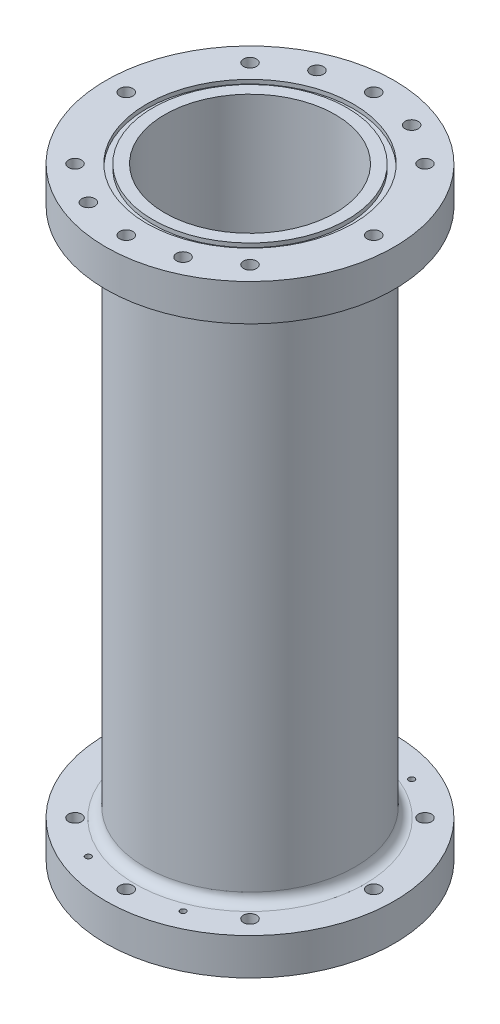
from build123d import *

# Parameters (mm, degrees)
SKETCH2_R               = 50.8
SKETCH2_R_2             = 41.275
BASE_CYLINDER_DEPTH     = 292.1
SKETCH3_R               = 69.85
SKETCH3_R_2             = 41.275
AFT_FLANGE_DEPTH        = 17.78
SKETCH4_R               = 69.85
SKETCH4_R_2             = 41.275
FORWARD_FLANGE_DEPTH    = 17.78
SKETCH6_R               = 50.0761
SKETCH6_R_2             = 47.0027
O_RING_SLOT_1_DEPTH     = 1.9812
SKETCH7_R               = 50.0761
SKETCH7_R_2             = 47.0027
O_RING_SLOT_2_DEPTH     = 1.9812
SKETCH8_R               = 3.175
CUT_EXTRUDE4_DEPTH      = 1
CUT_EXTRUDE4_DEPTH_BACK = 293.1
FILLET1_R               = 4.7625
SKETCH9_R               = 3.175
CUT_EXTRUDE5_DEPTH      = 7.62
SKETCH10_R              = 3.175
CUT_EXTRUDE6_DEPTH      = 7.62
CUT_EXTRUDE7_REACH      = 286.48
SKETCH11_R              = 1.4097
CUT_EXTRUDE8_REACH      = 286.48
SKETCH12_R              = 1.4097


with BuildPart() as part:
    # Sketch2 → Base Cylinder (new body)
    with BuildSketch(Plane(origin=(0, 0, 0), x_dir=(1, 0, 0), z_dir=(0, 1, 0))):
        Circle(SKETCH2_R)
        Circle(SKETCH2_R_2, mode=Mode.SUBTRACT)
    extrude(amount=BASE_CYLINDER_DEPTH)

    # Sketch3 → Aft Flange (add)
    with BuildSketch(Plane.XZ):
        Circle(SKETCH3_R)
        Circle(SKETCH3_R_2, mode=Mode.SUBTRACT)
    extrude(amount=-AFT_FLANGE_DEPTH)

    # Sketch4 → Forward Flange (add)
    with BuildSketch(Plane(origin=(0, 292.1, 0), x_dir=(1, 0, 0), z_dir=(0, 1, 0))):
        Circle(SKETCH4_R)
        Circle(SKETCH4_R_2, mode=Mode.SUBTRACT)
    extrude(amount=-FORWARD_FLANGE_DEPTH)

    # Sketch6 → O-Ring Slot 1 (cut)
    with BuildSketch(Plane.XZ):
        Circle(SKETCH6_R)
        Circle(SKETCH6_R_2, mode=Mode.SUBTRACT)
    extrude(amount=-O_RING_SLOT_1_DEPTH, mode=Mode.SUBTRACT)

    # Sketch7 → O-Ring Slot 2 (cut)
    with BuildSketch(Plane(origin=(0, 292.1, 0), x_dir=(1, 0, 0), z_dir=(0, 1, 0))):
        Circle(SKETCH7_R)
        Circle(SKETCH7_R_2, mode=Mode.SUBTRACT)
    extrude(amount=-O_RING_SLOT_2_DEPTH, mode=Mode.SUBTRACT)

    # Sketch8 → Cut-Extrude4 (cut, two sides)
    with BuildSketch(Plane.XZ) as cut_extrude4_sk:
        with Locations((-59.9186, 0)):
            Circle(SKETCH8_R)
        with Locations((-42.368848379, 42.368848379)):
            Circle(SKETCH8_R)
        with Locations((0, 59.9186)):
            Circle(SKETCH8_R)
        with Locations((42.368848379, 42.368848379)):
            Circle(SKETCH8_R)
        with Locations((59.9186, 0)):
            Circle(SKETCH8_R)
        with Locations((42.368848379, -42.368848379)):
            Circle(SKETCH8_R)
        with Locations((0, -59.9186)):
            Circle(SKETCH8_R)
        with Locations((-42.368848379, -42.368848379)):
            Circle(SKETCH8_R)
    extrude(amount=CUT_EXTRUDE4_DEPTH, mode=Mode.SUBTRACT)
    extrude(cut_extrude4_sk.sketch, amount=-CUT_EXTRUDE4_DEPTH_BACK, mode=Mode.SUBTRACT)

    # Fillet1
    fillet1_edges = [part.edges().sort_by_distance(p)[0] for p in [
        (-50.8, 17.78, 0),
        (-50.8, 274.32, 0),
    ]]
    fillet(fillet1_edges, radius=FILLET1_R)

    # Sketch9 → Cut-Extrude5 (cut)
    with BuildSketch(Plane(origin=(0, 292.1, 0), x_dir=(1, 0, 0), z_dir=(0, 1, 0))):
        with Locations((-22.929855511, 55.357568157)):
            Circle(SKETCH9_R)
        with Locations((22.929855511, -55.357568157)):
            Circle(SKETCH9_R)
        with Locations((22.929855511, 55.357568157)):
            Circle(SKETCH9_R)
        with Locations((-22.929855511, -55.357568157)):
            Circle(SKETCH9_R)
    extrude(amount=-CUT_EXTRUDE5_DEPTH, mode=Mode.SUBTRACT)

    # Sketch10 → Cut-Extrude6 (cut)
    with BuildSketch(Plane.XZ):
        with Locations((-22.929855511, 55.357568157)):
            Circle(SKETCH10_R)
        with Locations((22.929855511, -55.357568157)):
            Circle(SKETCH10_R)
        with Locations((22.929855511, 55.357568157)):
            Circle(SKETCH10_R)
        with Locations((-22.929855511, -55.357568157)):
            Circle(SKETCH10_R)
    extrude(amount=-CUT_EXTRUDE6_DEPTH, mode=Mode.SUBTRACT)

    # Sketch11 → Cut-Extrude7 (cut, up to next)
    with BuildSketch(Plane(origin=(0, 284.48, 0), x_dir=(1, 0, 0), z_dir=(0, 1, 0)), mode=Mode.PRIVATE) as cut_extrude7_sk1:
        with Locations((-22.929855511, 55.357568157)):
            Circle(SKETCH11_R)
    cut_extrude7_tool1 = extrude(cut_extrude7_sk1.sketch, amount=-CUT_EXTRUDE7_REACH, mode=Mode.PRIVATE) & part.part
    add(cut_extrude7_tool1.solids().sort_by_distance((-22.929856, 284.48, -55.357568))[0], mode=Mode.SUBTRACT)
    # Sketch11 → Cut-Extrude7 (cut, up to next)
    with BuildSketch(Plane(origin=(0, 284.48, 0), x_dir=(1, 0, 0), z_dir=(0, 1, 0)), mode=Mode.PRIVATE) as cut_extrude7_sk2:
        with Locations((22.929855511, 55.357568157)):
            Circle(SKETCH11_R)
    cut_extrude7_tool2 = extrude(cut_extrude7_sk2.sketch, amount=-CUT_EXTRUDE7_REACH, mode=Mode.PRIVATE) & part.part
    add(cut_extrude7_tool2.solids().sort_by_distance((22.929856, 284.48, -55.357568))[0], mode=Mode.SUBTRACT)
    # Sketch11 → Cut-Extrude7 (cut, up to next)
    with BuildSketch(Plane(origin=(0, 284.48, 0), x_dir=(1, 0, 0), z_dir=(0, 1, 0)), mode=Mode.PRIVATE) as cut_extrude7_sk3:
        with Locations((-22.929855511, -55.357568157)):
            Circle(SKETCH11_R)
    cut_extrude7_tool3 = extrude(cut_extrude7_sk3.sketch, amount=-CUT_EXTRUDE7_REACH, mode=Mode.PRIVATE) & part.part
    add(cut_extrude7_tool3.solids().sort_by_distance((-22.929856, 284.48, 55.357568))[0], mode=Mode.SUBTRACT)
    # Sketch11 → Cut-Extrude7 (cut, up to next)
    with BuildSketch(Plane(origin=(0, 284.48, 0), x_dir=(1, 0, 0), z_dir=(0, 1, 0)), mode=Mode.PRIVATE) as cut_extrude7_sk4:
        with Locations((22.929855511, -55.357568157)):
            Circle(SKETCH11_R)
    cut_extrude7_tool4 = extrude(cut_extrude7_sk4.sketch, amount=-CUT_EXTRUDE7_REACH, mode=Mode.PRIVATE) & part.part
    add(cut_extrude7_tool4.solids().sort_by_distance((22.929856, 284.48, 55.357568))[0], mode=Mode.SUBTRACT)

    # Sketch12 → Cut-Extrude8 (cut, up to next)
    with BuildSketch(Plane.XZ.offset(-7.62), mode=Mode.PRIVATE) as cut_extrude8_sk1:
        with Locations((-22.929855511, 55.357568157)):
            Circle(SKETCH12_R)
    cut_extrude8_tool1 = extrude(cut_extrude8_sk1.sketch, amount=-CUT_EXTRUDE8_REACH, mode=Mode.PRIVATE) & part.part
    add(cut_extrude8_tool1.solids().sort_by_distance((-22.929856, 7.62, 55.357568))[0], mode=Mode.SUBTRACT)
    # Sketch12 → Cut-Extrude8 (cut, up to next)
    with BuildSketch(Plane.XZ.offset(-7.62), mode=Mode.PRIVATE) as cut_extrude8_sk2:
        with Locations((22.929855511, 55.357568157)):
            Circle(SKETCH12_R)
    cut_extrude8_tool2 = extrude(cut_extrude8_sk2.sketch, amount=-CUT_EXTRUDE8_REACH, mode=Mode.PRIVATE) & part.part
    add(cut_extrude8_tool2.solids().sort_by_distance((22.929856, 7.62, 55.357568))[0], mode=Mode.SUBTRACT)
    # Sketch12 → Cut-Extrude8 (cut, up to next)
    with BuildSketch(Plane.XZ.offset(-7.62), mode=Mode.PRIVATE) as cut_extrude8_sk3:
        with Locations((-22.929855511, -55.357568157)):
            Circle(SKETCH12_R)
    cut_extrude8_tool3 = extrude(cut_extrude8_sk3.sketch, amount=-CUT_EXTRUDE8_REACH, mode=Mode.PRIVATE) & part.part
    add(cut_extrude8_tool3.solids().sort_by_distance((-22.929856, 7.62, -55.357568))[0], mode=Mode.SUBTRACT)
    # Sketch12 → Cut-Extrude8 (cut, up to next)
    with BuildSketch(Plane.XZ.offset(-7.62), mode=Mode.PRIVATE) as cut_extrude8_sk4:
        with Locations((22.929855511, -55.357568157)):
            Circle(SKETCH12_R)
    cut_extrude8_tool4 = extrude(cut_extrude8_sk4.sketch, amount=-CUT_EXTRUDE8_REACH, mode=Mode.PRIVATE) & part.part
    add(cut_extrude8_tool4.solids().sort_by_distance((22.929856, 7.62, -55.357568))[0], mode=Mode.SUBTRACT)


solid = part.part
